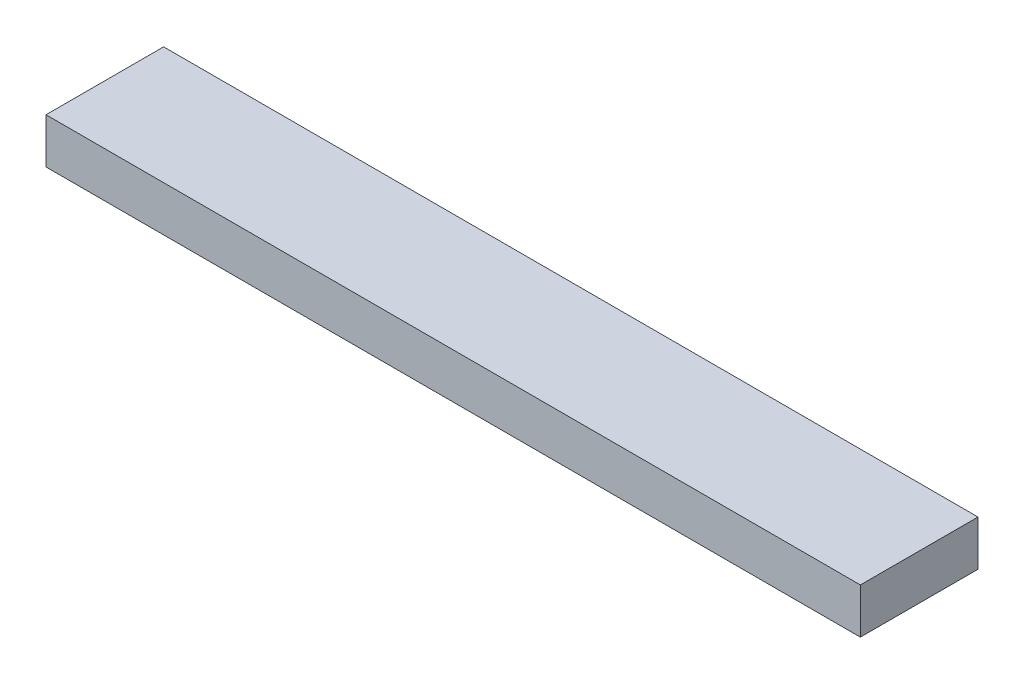
from build123d import *

# Parameters (mm, degrees)
SKETCH1_W           = 114.3
SKETCH1_H           = 16.51
BOSS_EXTRUDE1_DEPTH = 6.35


with BuildPart() as part:
    # Sketch1 → Boss-Extrude1 (new body)
    with BuildSketch(Plane(origin=(0, 0, 0), x_dir=(1, 0, 0), z_dir=(0, 1, 0))):
        Rectangle(SKETCH1_W, SKETCH1_H)
    extrude(amount=BOSS_EXTRUDE1_DEPTH)


solid = part.part
